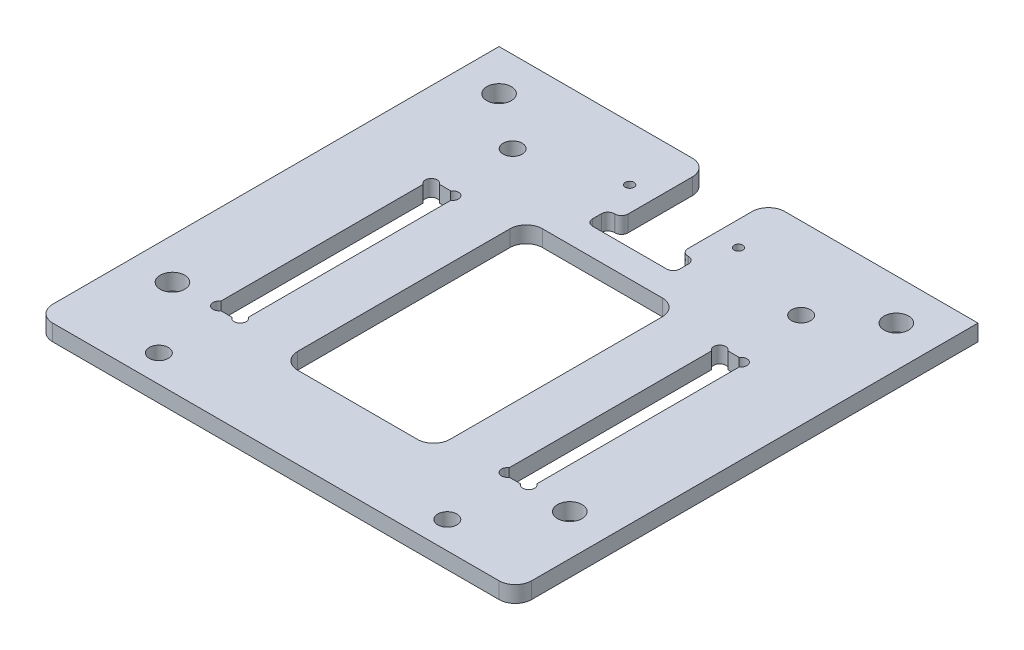
from build123d import *

# Parameters (mm, degrees)
SKETCH_1_W          = 88
SKETCH_1_H          = 85
EXTRUDE_1_DEPTH     = 3
SKETCH_2_R          = 1.75
SKETCH_2_R_2        = 1.1
SKETCH_2_W          = 5.1
SKETCH_2_H          = 40.2
SKETCH_2_R_3        = 2.25
SKETCH_2_W_2        = 28
SKETCH_2_H_2        = 45
CUT_EXTRUDE_1_DEPTH = 3
M2X0_4_1_D          = 1.6
M2X0_4_1_DEPTH      = 6
M2X0_4_1_TIP        = 0.480688495
CUT_EXTRUDE_2_DEPTH = 4
FILLET_7_R          = 3
FILLET_6_R          = 1.2


with BuildPart() as part:
    # ｽｹｯﾁ1 → ﾎﾞｽ - 押し出し1 (new body)
    with BuildSketch(Plane(origin=(0, 0, 0), x_dir=(1, 0, 0), z_dir=(0, 1, 0))):
        Rectangle(SKETCH_1_W, SKETCH_1_H)
    extrude(amount=EXTRUDE_1_DEPTH)

    # ｽｹｯﾁ2 → ｶｯﾄ - 押し出し1 (cut)
    with BuildSketch(Plane(origin=(0, 3, 0), x_dir=(1, 0, 0), z_dir=(0, 1, 0))):
        with Locations((-26.5, 27.5)):
            Circle(SKETCH_2_R)
        with Locations((26.5, 27.5)):
            Circle(SKETCH_2_R)
        with Locations((-28.45, -24.5)):
            Circle(SKETCH_2_R_2)
        with Locations((-24.55, -24.5)):
            Circle(SKETCH_2_R_2)
        with Locations((-26.5, -5)):
            Rectangle(SKETCH_2_W, SKETCH_2_H)
        with Locations((-28.45, 14.5)):
            Circle(SKETCH_2_R_2)
        with Locations((-24.55, 14.5)):
            Circle(SKETCH_2_R_2)
        with Locations((26.5, -5)):
            Rectangle(SKETCH_2_W, SKETCH_2_H)
        with Locations((24.55, 14.5)):
            Circle(SKETCH_2_R_2)
        with Locations((28.45, 14.5)):
            Circle(SKETCH_2_R_2)
        with Locations((24.55, -24.5)):
            Circle(SKETCH_2_R_2)
        with Locations((28.45, -24.5)):
            Circle(SKETCH_2_R_2)
        with Locations((-26.5, -37.5)):
            Circle(SKETCH_2_R)
        with Locations((26.5, -37.5)):
            Circle(SKETCH_2_R)
        with Locations((-36.5, -25)):
            Circle(SKETCH_2_R_3)
        with Locations((-36.5, 35)):
            Circle(SKETCH_2_R_3)
        with Locations((36.5, 35)):
            Circle(SKETCH_2_R_3)
        with Locations((36.5, -25)):
            Circle(SKETCH_2_R_3)
        with Locations((0, -5)):
            Rectangle(SKETCH_2_W_2, SKETCH_2_H_2)
    extrude(amount=-CUT_EXTRUDE_1_DEPTH, mode=Mode.SUBTRACT)

    # M2x0.4 ねじ穴1
    with Locations(Plane(origin=(0, 3, 0), x_dir=(1, 0, 0), z_dir=(0, 1, 0))):
        with Locations((-10, 32.5), (10, 32.5)):
            Hole(M2X0_4_1_D / 2, depth=M2X0_4_1_DEPTH)
            with Locations((0, 0, -(M2X0_4_1_DEPTH + M2X0_4_1_TIP / 2))):  # 118° drill point
                Cone(0, M2X0_4_1_D / 2, M2X0_4_1_TIP, mode=Mode.SUBTRACT)

    # ｽｹｯﾁ5 → ｶｯﾄ - 押し出し2 (cut, through all)
    with BuildSketch(Plane(origin=(0, 3, 0), x_dir=(1, 0, 0), z_dir=(0, 1, 0))):
        Polygon((-5.5, 42.5), (5.5, 42.5), (5.5, 26.5), (8, 26.5), (8, 22.5), (-8, 22.5), (-8, 26.5), (-5.5, 26.5), align=None)
    extrude(amount=-CUT_EXTRUDE_2_DEPTH, mode=Mode.SUBTRACT)

    # ﾌｨﾚｯﾄ7
    fillet_7_edges = [part.edges().sort_by_distance(p)[0] for p in [
        (-5.5, 1.5, -42.5),
        (5.5, 1.5, -42.5),
        (-14, 1.5, -17.5),
        (14, 1.5, -17.5),
        (14, 1.5, 27.5),
        (-14, 1.5, 27.5),
        (44, 1.5, 42.5),
        (-44, 1.5, 42.5),
    ]]
    fillet(fillet_7_edges, radius=FILLET_7_R)

    # ﾌｨﾚｯﾄ6
    fillet_6_edges = [part.edges().sort_by_distance(p)[0] for p in [
        (5.5, 1.5, -26.5),
        (8, 1.5, -26.5),
        (8, 1.5, -22.5),
        (-8, 1.5, -22.5),
        (-8, 1.5, -26.5),
        (-5.5, 1.5, -26.5),
    ]]
    fillet(fillet_6_edges, radius=FILLET_6_R)


solid = part.part
